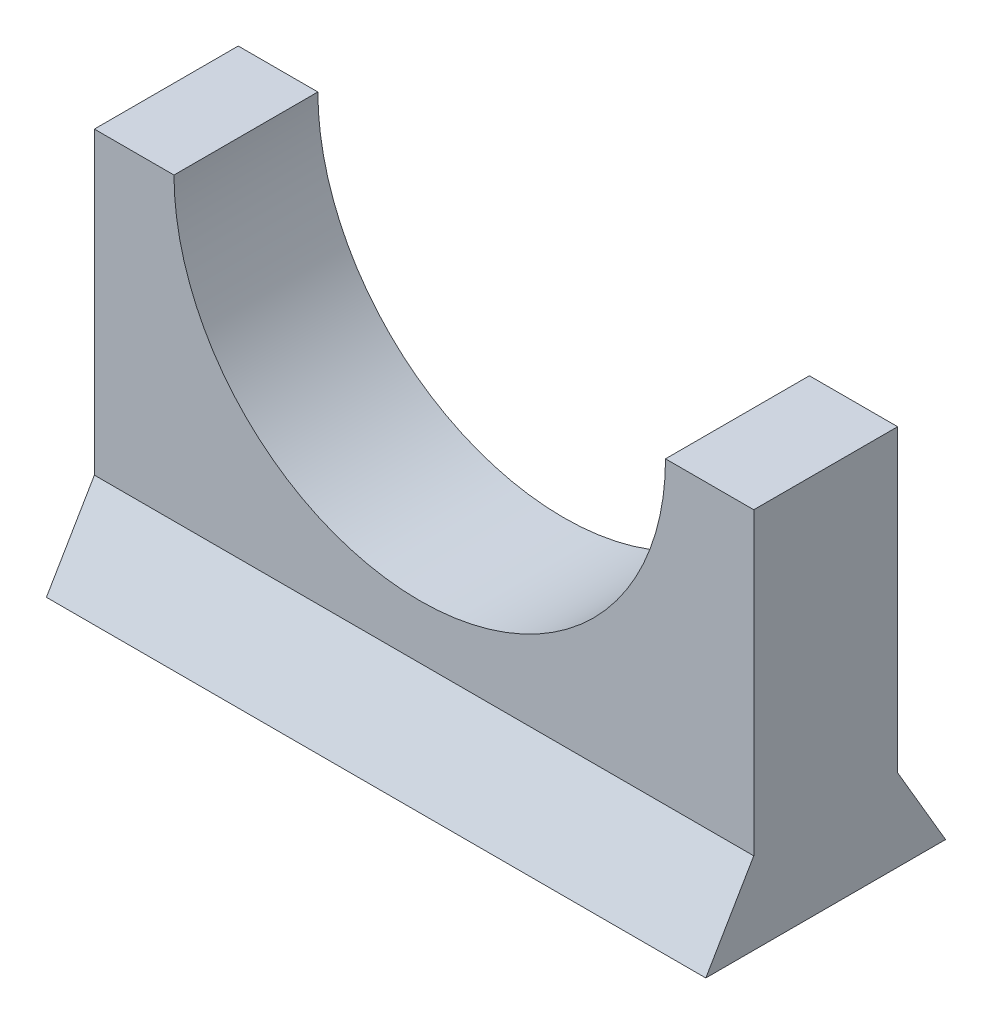
from build123d import *

# Parameters (mm, degrees)
SKETCH1_W           = 139.7
SKETCH1_H           = 76.2
BOSS_EXTRUDE1_DEPTH = 50.8
CUT_EXTRUDE1_DEPTH  = 140.7
SKETCH3_W           = 139.7
SKETCH3_H           = 15.24
BOSS_EXTRUDE2_DEPTH = 63.5
CUT_EXTRUDE4_DEPTH  = 63.5


with BuildPart() as part:
    # Sketch1 → Boss-Extrude1 (new body)
    with BuildSketch(Plane.XY):
        with Locations((69.85, 38.1)):
            Rectangle(SKETCH1_W, SKETCH1_H)
    extrude(amount=BOSS_EXTRUDE1_DEPTH)

    # Sketch2 → Cut-Extrude1 (cut, through all)
    with BuildSketch(Plane(origin=(139.7, 0, 0), x_dir=(0, 0, -1), z_dir=(1, 0, 0))):
        Polygon((-50.8, 76.2), (-50.8, 0), (-40.64, 17.335178993), (-25.4, 17.335178993), (-10.16, 17.335178993), (0, 0), (0, 76.2), align=None)
    extrude(amount=-CUT_EXTRUDE1_DEPTH, mode=Mode.SUBTRACT)

    # Sketch3 → Boss-Extrude2 (add)
    with BuildSketch(Plane(origin=(0, 17.335178993, 0), x_dir=(1, 0, 0), z_dir=(0, 1, 0))):
        with Locations((69.85, -33.02)):
            Rectangle(SKETCH3_W, SKETCH3_H)
        with Locations((69.85, -17.78)):
            Rectangle(SKETCH3_W, SKETCH3_H)
    extrude(amount=BOSS_EXTRUDE2_DEPTH)

    # Sketch7 → Cut-Extrude4 (cut)
    with BuildSketch(Plane.XY.offset(40.64)):
        with BuildLine():
            Line((16.865330571, 80.835178993), (121.005330571, 80.835178993))
            ThreePointArc((121.005330571, 80.835178993), (68.935330571, 28.765178993), (16.865330571, 80.835178993))
        make_face()
    extrude(amount=-CUT_EXTRUDE4_DEPTH, mode=Mode.SUBTRACT)


solid = part.part
